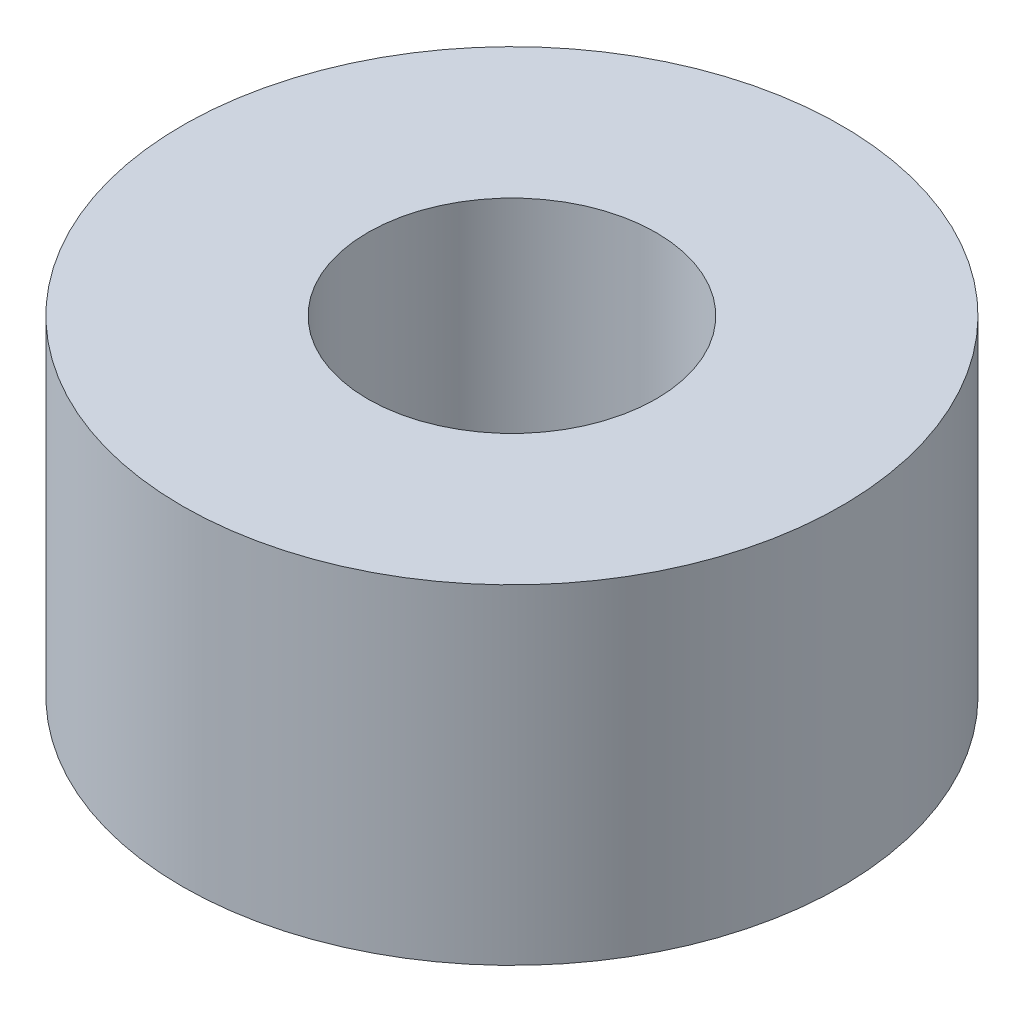
from build123d import *

# Parameters (mm, degrees)
SKETCH_1_R      = 4
SKETCH_1_R_2    = 1.75
EXTRUDE_1_DEPTH = 4


with BuildPart() as part:
    # Эскиз1 → Бобышка-Вытянуть1 (new body)
    with BuildSketch(Plane(origin=(0, 0, 0), x_dir=(1, 0, 0), z_dir=(0, 1, 0))):
        Circle(SKETCH_1_R)
        Circle(SKETCH_1_R_2, mode=Mode.SUBTRACT)
    extrude(amount=EXTRUDE_1_DEPTH)


solid = part.part
